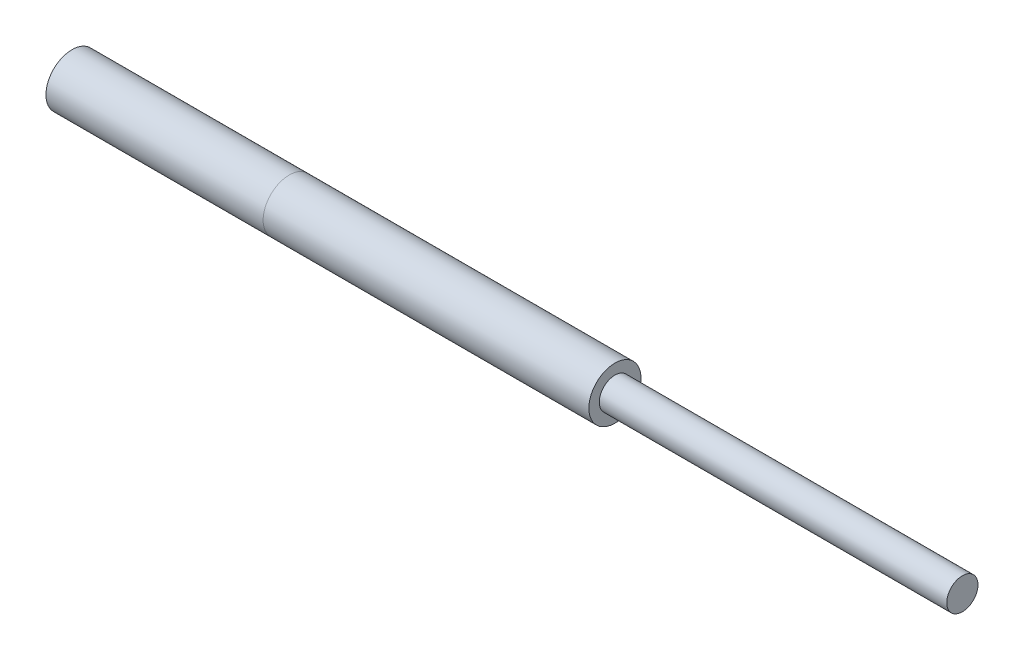
from build123d import *

# Parameters (mm, degrees)
SKETCH1_R           = 30
SKETCH1_R_2         = 20
BOSS_EXTRUDE1_DEPTH = 250
SKETCH3_R           = 30
BOSS_EXTRUDE2_DEPTH = 375
SKETCH4_R           = 18
BOSS_EXTRUDE3_DEPTH = 400


with BuildPart() as part:
    # Sketch1 → Boss-Extrude1 (new body)
    with BuildSketch(Plane(origin=(0, 0, 0), x_dir=(0, 0, -1), z_dir=(1, 0, 0))):
        Circle(SKETCH1_R)
        Circle(SKETCH1_R_2, mode=Mode.SUBTRACT)
    extrude(amount=BOSS_EXTRUDE1_DEPTH)


with BuildPart() as body_2:
    # Sketch3 → Boss-Extrude2 (new body)
    with BuildSketch(Plane(origin=(250, 0, 0), x_dir=(0, 0, -1), z_dir=(1, 0, 0))):
        Circle(SKETCH3_R)
    extrude(amount=BOSS_EXTRUDE2_DEPTH)


with BuildPart() as body_3:
    # Sketch4 → Boss-Extrude3 (new body)
    with BuildSketch(Plane(origin=(625, 0, 0), x_dir=(0, 0, -1), z_dir=(1, 0, 0))):
        Circle(SKETCH4_R)
    extrude(amount=BOSS_EXTRUDE3_DEPTH)


solid = Compound([part.part, body_2.part, body_3.part])
